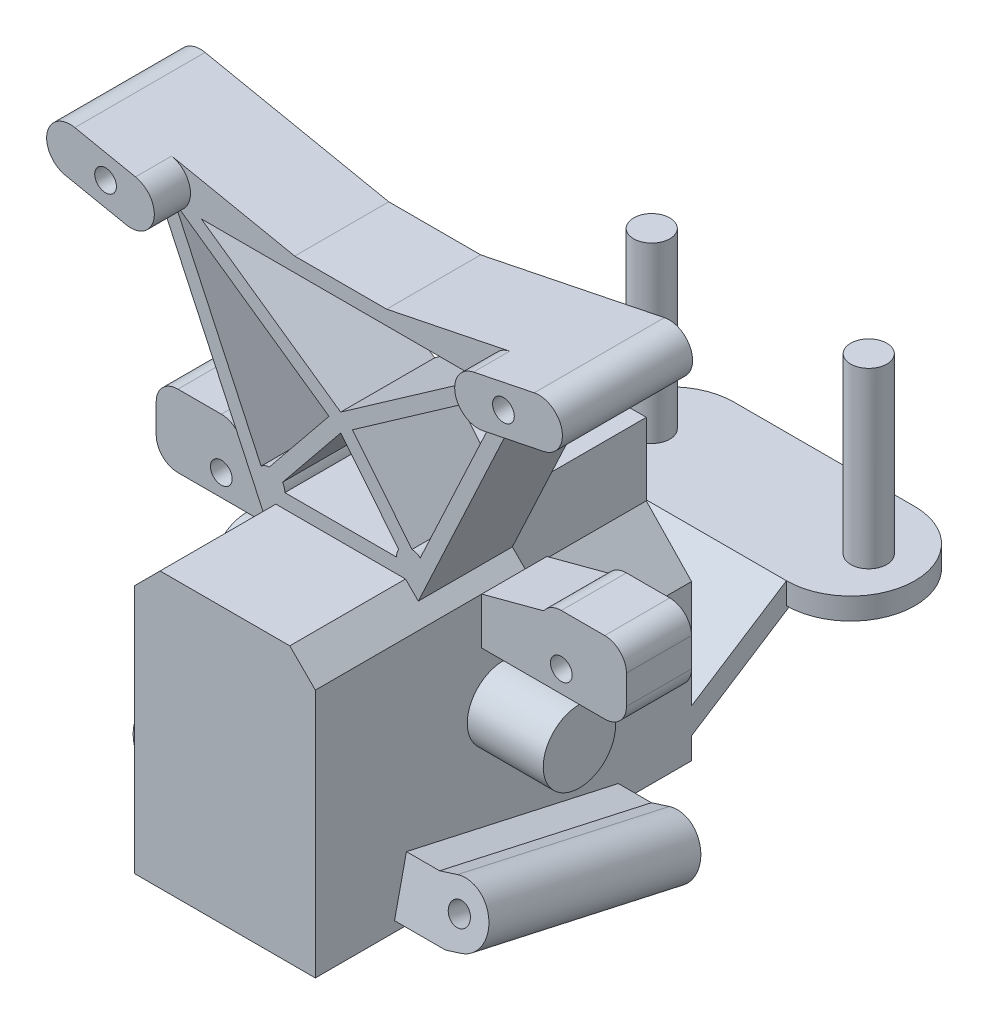
from build123d import *

# Parameters (mm, degrees)
SKETCH1_R                    = 5
DRIVELINE_AXIS_DEPTH         = 23
DUMMY_BOSS_DEPTH             = 26
SKETCH8_R                    = 1.5
UPRIGHTS_DEPTH               = 10
UPRIGHTS_DEPTH_BACK          = 3
SKETCH9_R                    = 1.5
SHOCK_MOUNT_DEPTH            = 5
SHOCK_MOUNT_DEPTH_BACK       = 13
SKETCH10_R                   = 1.5
TURNBUCKLE_MOUNTS_DEPTH      = 3
TURNBUCKLE_MOUNTS_DEPTH_BACK = 6
TURNBUCKLE_ROOM_DEPTH        = 1
TURNBUCKLE_ROOM_DEPTH_BACK   = 23
BOSS_EXTRUDE2_DEPTH          = 12.5
BOSS_EXTRUDE3_DEPTH          = 3
SKETCH43_R                   = 2.5
BOSS_EXTRUDE4_DEPTH          = 24
BOSS_EXTRUDE5_DEPTH          = 15
BOSS_EXTRUDE6_DEPTH          = 12.5
SKETCH49_R                   = 1.5
CUT_EXTRUDE1_DEPTH           = 15


with BuildPart() as part:
    # Sketch1 → Driveline Axis (new body, symmetric)
    with BuildSketch(Plane(origin=(0, 0, 0), x_dir=(0, 0, -1), z_dir=(1, 0, 0))):
        Circle(SKETCH1_R)
    extrude(amount=DRIVELINE_AXIS_DEPTH, both=True)

    # Sketch2 → Dummy Boss (add, symmetric)
    with BuildSketch(Plane.XY):
        Polygon((-12.5, -20), (-12.5, 14.464466094), (-8.964466094, 18), (8.964466094, 18), (12.5, 14.464466094), (12.5, -20), align=None)
    extrude(amount=DUMMY_BOSS_DEPTH, both=True)

    # Sketch8 → Uprights (add, two sides)
    with BuildSketch(Plane.XY) as uprights_sk:
        with BuildLine():
            Line((-10.732233047, 16.232233047), (-24.661465898, 46.103569293))
            Line((-24.661465898, 46.103569293), (-33.048979486, 47.815663334))
            ThreePointArc((-33.048979486, 47.815663334), (-35.583316151, 51.65), (-31.748979486, 54.184336666))
            Line((-31.748979486, 54.184336666), (-6.351020514, 49))
            Line((-6.351020514, 49), (6.351020514, 49))
            Line((6.351020514, 49), (31.748979486, 54.184336666))
            ThreePointArc((31.748979486, 54.184336666), (35.583316151, 51.65), (33.048979486, 47.815663334))
            Line((33.048979486, 47.815663334), (24.661465898, 46.103569293))
            Line((24.661465898, 46.103569293), (10.732233047, 16.232233047))
            Line((10.732233047, 16.232233047), (8.964466094, 18))
            Line((8.964466094, 18), (-8.964466094, 18))
            Line((-8.964466094, 18), (-10.732233047, 16.232233047))
        make_face()
        with Locations((-27.5, 50)):
            Circle(SKETCH8_R, mode=Mode.SUBTRACT)
        with Locations((27.5, 50)):
            Circle(SKETCH8_R, mode=Mode.SUBTRACT)
        with BuildLine():
            Line((9.866245938, 21.994232403), (1.612099151, 32.1872548))
            Line((1.612099151, 32.1872548), (22.924030195, 47.110029571))
            Line((22.924030195, 47.110029571), (10.997739753, 21.534017182))
            ThreePointArc((10.997739753, 21.534017182), (10.467987263, 21.852621345), (9.866245938, 21.994232403))
        make_face(mode=Mode.SUBTRACT)
        with BuildLine():
            Line((7.714466094, 20), (-7.714466094, 20))
            ThreePointArc((-7.714466094, 20), (-7.795487149, 20.563488959), (-8.031985901, 21.081323449))
            Line((-8.031985901, 21.081323449), (0, 31))
            Line((0, 31), (8.031985901, 21.081323449))
            ThreePointArc((8.031985901, 21.081323449), (7.795487149, 20.563488959), (7.714466094, 20))
        make_face(mode=Mode.SUBTRACT)
        with BuildLine():
            Line((-10.997739753, 21.534017182), (-22.924030195, 47.110029571))
            Line((-22.924030195, 47.110029571), (-1.612099151, 32.1872548))
            Line((-1.612099151, 32.1872548), (-9.866245938, 21.994232403))
            ThreePointArc((-9.866245938, 21.994232403), (-10.467987263, 21.852621345), (-10.997739753, 21.534017182))
        make_face(mode=Mode.SUBTRACT)
        Polygon((-19.279998091, 47), (0, 33.5), (19.279998091, 47), align=None, mode=Mode.SUBTRACT)
    extrude(amount=UPRIGHTS_DEPTH)
    extrude(uprights_sk.sketch, amount=-UPRIGHTS_DEPTH_BACK)

    # Sketch9 → Shock Mount (add, two sides)
    with BuildSketch(Plane.XY.offset(10)) as shock_mount_sk:
        with BuildLine():
            Line((-24.661465898, 46.103569293), (-33.048979486, 47.815663334))
            ThreePointArc((-33.048979486, 47.815663334), (-35.583316151, 51.65), (-31.748979486, 54.184336666))
            Line((-31.748979486, 54.184336666), (-23.361465898, 52.472242624))
            ThreePointArc((-23.361465898, 52.472242624), (-20.827129232, 48.637905958), (-24.661465898, 46.103569293))
        make_face()
        with Locations((-27.5, 50)):
            Circle(SKETCH9_R, mode=Mode.SUBTRACT)
        with BuildLine():
            Line((23.361465898, 52.472242624), (31.748979486, 54.184336666))
            ThreePointArc((31.748979486, 54.184336666), (35.583316151, 51.65), (33.048979486, 47.815663334))
            Line((33.048979486, 47.815663334), (24.661465898, 46.103569293))
            ThreePointArc((24.661465898, 46.103569293), (20.827129232, 48.637905958), (23.361465898, 52.472242624))
        make_face()
        with Locations((27.5, 50)):
            Circle(SKETCH9_R, mode=Mode.SUBTRACT)
    extrude(amount=SHOCK_MOUNT_DEPTH)
    extrude(shock_mount_sk.sketch, amount=-SHOCK_MOUNT_DEPTH_BACK)

    # Sketch10 → Turnbuckle Mounts (add, two sides)
    with BuildSketch(Plane.XY) as turnbuckle_mounts_sk:
        with BuildLine():
            Line((29.5, 8), (12.5, 8))
            Line((12.5, 8), (12.5, 14.464466094))
            Line((12.5, 14.464466094), (21.055616084, 16.739249053))
            ThreePointArc((21.055616084, 16.739249053), (22.124817677, 17.666247097), (23.5, 18))
            Line((23.5, 18), (29.5, 18))
            ThreePointArc((29.5, 18), (31.621320344, 17.121320344), (32.5, 15))
            Line((32.5, 15), (32.5, 11))
            ThreePointArc((32.5, 11), (31.621320344, 8.878679656), (29.5, 8))
        make_face()
        with Locations((23.5, 11)):
            Circle(SKETCH10_R, mode=Mode.SUBTRACT)
        with BuildLine():
            Line((-12.5, 14.464466094), (-21.055616084, 16.739249053))
            ThreePointArc((-21.055616084, 16.739249053), (-22.124817677, 17.666247097), (-23.5, 18))
            Line((-23.5, 18), (-29.5, 18))
            ThreePointArc((-29.5, 18), (-31.621320344, 17.121320344), (-32.5, 15))
            Line((-32.5, 15), (-32.5, 11))
            ThreePointArc((-32.5, 11), (-31.621320344, 8.878679656), (-29.5, 8))
            Line((-29.5, 8), (-12.5, 8))
            Line((-12.5, 8), (-12.5, 14.464466094))
        make_face()
        with Locations((-23.5, 11)):
            Circle(SKETCH10_R, mode=Mode.SUBTRACT)
    extrude(amount=TURNBUCKLE_MOUNTS_DEPTH)
    extrude(turnbuckle_mounts_sk.sketch, amount=-TURNBUCKLE_MOUNTS_DEPTH_BACK)

    # Sketch11 → Turnbuckle Room (cut, two sides)
    with BuildSketch(Plane(origin=(0, 0, -26), x_dir=(-1, 0, 0), z_dir=(0, 0, -1))) as turnbuckle_room_sk:
        Polygon((8.964466094, 18), (5.75, 18), (5.75, 8), (12.5, 1.544903812), (12.5, 14.464466094), align=None)
        Polygon((-12.5, 14.464466094), (-12.5, 1.464466094), (-6.25, 8), (-6.25, 18), (-8.964466094, 18), align=None)
    extrude(amount=TURNBUCKLE_ROOM_DEPTH, mode=Mode.SUBTRACT)
    extrude(turnbuckle_room_sk.sketch, amount=-TURNBUCKLE_ROOM_DEPTH_BACK, mode=Mode.SUBTRACT)

    # Sketch40 → Boss-Extrude2 (add, symmetric)
    with BuildSketch(Plane(origin=(0, 0, 0), x_dir=(0, 0, -1), z_dir=(1, 0, 0))):
        Polygon((26, -13.433574933), (39.118894341, -5), (56.881105659, -5), (56.881105659, -8), (40, -8), (26, -17), align=None)
    extrude(amount=BOSS_EXTRUDE2_DEPTH, both=True)

    # Sketch41 → Boss-Extrude3 (add)
    with BuildSketch(Plane(origin=(0, -5, 0), x_dir=(1, 0, 0), z_dir=(0, 1, 0))):
        with BuildLine():
            Line((12.5, 56.881105659), (12.5, 39.118894341))
            ThreePointArc((12.5, 39.118894341), (21.381105659, 48), (12.5, 56.881105659))
        make_face()
    boss_extrude3 = extrude(amount=-BOSS_EXTRUDE3_DEPTH)

    # Mirror4: Boss-Extrude3 across plane
    add(boss_extrude3.mirror(Plane(origin=(0, 0, 0), x_dir=(0, 0, 1), z_dir=(1, 0, 0))))

    # Sketch43 → Boss-Extrude4 (add)
    with BuildSketch(Plane(origin=(0, -5, 0), x_dir=(1, 0, 0), z_dir=(0, 1, 0))):
        with Locations((-15, 48)):
            Circle(SKETCH43_R)
        with Locations((15, 48)):
            Circle(SKETCH43_R)
    extrude(amount=BOSS_EXTRUDE4_DEPTH)

    # Sketch47 → Boss-Extrude5 (add, symmetric)
    with BuildSketch(Plane(origin=(0, -0.93692213, -4.226182617), x_dir=(0, 0.976296007, -0.216439614), z_dir=(0, -0.216439614, -0.976296007))):
        with BuildLine():
            Line((-13.806627078, 12.5), (-13.806627078, 17.084049145))
            Line((-13.806627078, 17.084049145), (-13.149862777, 19.41536026))
            ThreePointArc((-13.149862777, 19.41536026), (-15.91536026, 24.350137223), (-20.850137223, 21.58463974))
            Line((-20.850137223, 21.58463974), (-21.423285097, 19.550141201))
            Line((-21.423285097, 19.550141201), (-21.423285097, 12.5))
            Line((-21.423285097, 12.5), (-13.806627078, 12.5))
        make_face()
    boss_extrude5 = extrude(amount=BOSS_EXTRUDE5_DEPTH, both=True)

    # Sketch48 → Boss-Extrude6 (add)
    with BuildSketch(Plane.ZY.offset(-12.5)):
        Polygon((-14.233775168, -25.098984039), (8.766255495, -20), (-15.364192715, -20), align=None)
    boss_extrude6 = extrude(amount=BOSS_EXTRUDE6_DEPTH)

    # Sketch49 → Cut-Extrude1 (cut, symmetric)
    with BuildSketch(Plane(origin=(0, -0.93692213, -4.226182617), x_dir=(0, 0.976296007, -0.216439614), z_dir=(0, -0.216439614, -0.976296007))):
        with Locations((-17, 20.5)):
            Circle(SKETCH49_R)
    cut_extrude1 = extrude(amount=CUT_EXTRUDE1_DEPTH, both=True, mode=Mode.SUBTRACT)

    # Mirror5: Boss-Extrude5, Boss-Extrude6, Cut-Extrude1 across plane
    add(boss_extrude5.mirror(Plane(origin=(0, 0, 0), x_dir=(0, 0, 1), z_dir=(1, 0, 0))))
    add(boss_extrude6.mirror(Plane(origin=(0, 0, 0), x_dir=(0, 0, 1), z_dir=(1, 0, 0))))
    add(cut_extrude1.mirror(Plane(origin=(0, 0, 0), x_dir=(0, 0, 1), z_dir=(1, 0, 0))), mode=Mode.SUBTRACT)


solid = part.part
